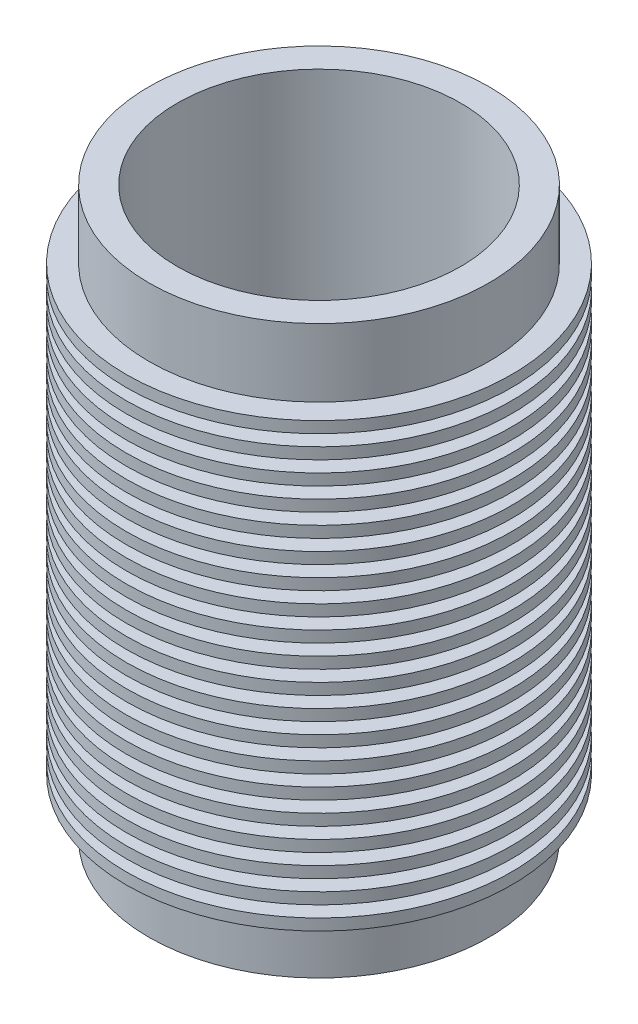
from build123d import *

# Parameters (mm, degrees)
SKETCH1_R               = 19.05
EXTRUDE1_DEPTH          = 31.75
EXTRUDE1_DEPTH_BACK     = 31.75
SKETCH2_R               = 15.875
CUT_EXTRUDE1_DEPTH      = 32.75
CUT_EXTRUDE1_DEPTH_BACK = 32.75
SKETCH3_R               = 21.59
SKETCH3_R_2             = 19.05
EXTRUDE_THIN1_DEPTH     = 1.27
LPATTERN1_COUNT         = 11
LPATTERN1_PITCH         = 2.54
LPATTERN1_COL_COUNT     = 10
LPATTERN1_COL_PITCH     = 2.54


with BuildPart() as part:
    # Sketch1 → Extrude1 (new body, two sides)
    with BuildSketch(Plane(origin=(0, 0, 0), x_dir=(1, 0, 0), z_dir=(0, 1, 0))) as extrude1_sk:
        Circle(SKETCH1_R)
    extrude(amount=EXTRUDE1_DEPTH)
    extrude(extrude1_sk.sketch, amount=-EXTRUDE1_DEPTH_BACK)

    # Sketch2 → Cut-Extrude1 (cut, two sides)
    with BuildSketch(Plane(origin=(0, 0, 0), x_dir=(1, 0, 0), z_dir=(0, 1, 0))) as cut_extrude1_sk:
        Circle(SKETCH2_R)
    extrude(amount=CUT_EXTRUDE1_DEPTH, mode=Mode.SUBTRACT)
    extrude(cut_extrude1_sk.sketch, amount=-CUT_EXTRUDE1_DEPTH_BACK, mode=Mode.SUBTRACT)

    # Sketch3 → Extrude-Thin1 (add)
    with BuildSketch(Plane(origin=(0, 0, 0), x_dir=(1, 0, 0), z_dir=(0, 1, 0))):
        Circle(SKETCH3_R)
        Circle(SKETCH3_R_2, mode=Mode.SUBTRACT)
    extrude_thin1 = extrude(amount=EXTRUDE_THIN1_DEPTH)

    # LPattern1: Extrude-Thin1 ×11
    with Locations(*[(0, -i * LPATTERN1_PITCH, 0) for i in range(1, LPATTERN1_COUNT)]):
        add(extrude_thin1)

    # LPattern1 col: Extrude-Thin1 ×10
    with Locations(*[(0, i * LPATTERN1_COL_PITCH, 0) for i in range(1, LPATTERN1_COL_COUNT)]):
        add(extrude_thin1)


solid = part.part
